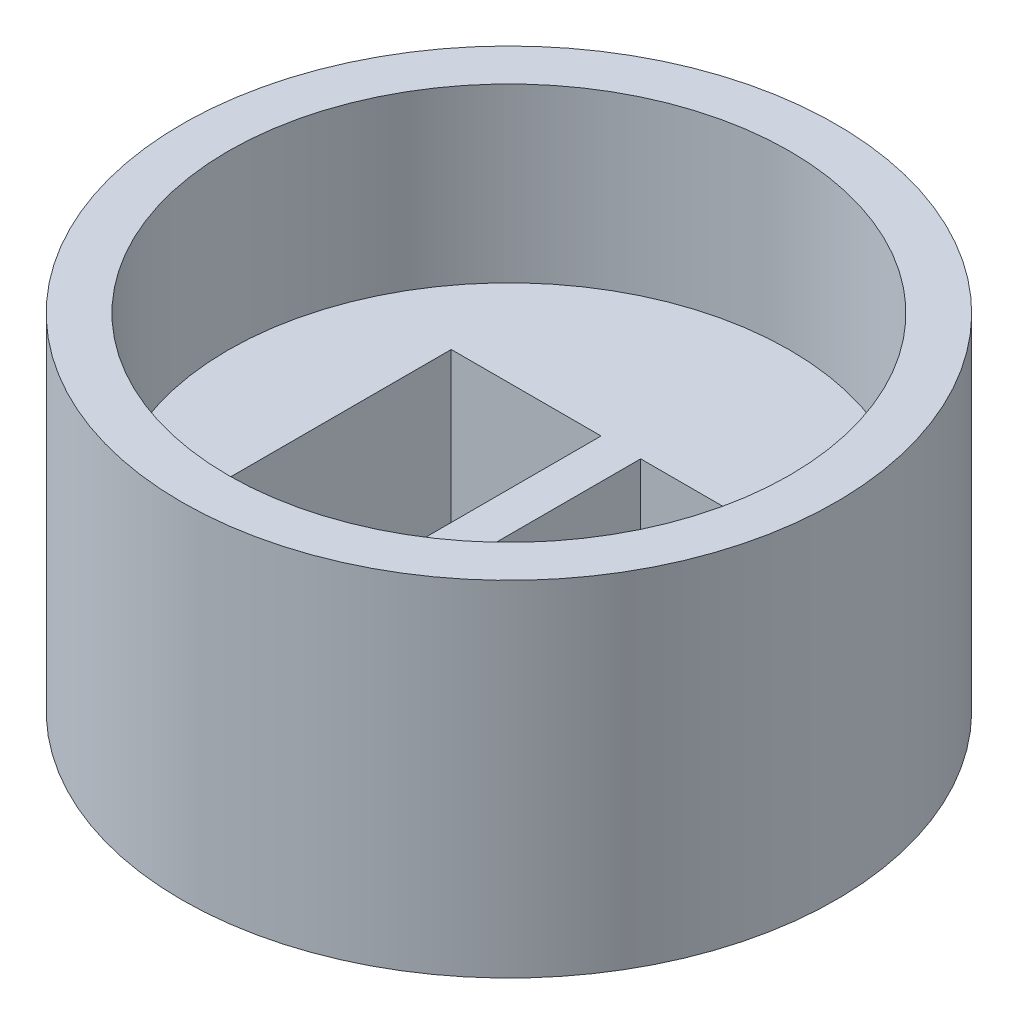
from build123d import *

# Parameters (mm, degrees)
SKETCH2_R           = 9.5
BOSS_EXTRUDE2_DEPTH = 10
SKETCH3_R           = 8.15
CUT_EXTRUDE1_DEPTH  = 5
SKETCH4_W           = 4.35
SKETCH4_H           = 6.5
CUT_EXTRUDE2_DEPTH  = 6


with BuildPart() as part:
    # Sketch2 → Boss-Extrude2 (new body)
    with BuildSketch(Plane(origin=(0, 0, 0), x_dir=(1, 0, 0), z_dir=(0, 1, 0))):
        Circle(SKETCH2_R)
    extrude(amount=BOSS_EXTRUDE2_DEPTH)

    # Sketch3 → Cut-Extrude1 (cut)
    with BuildSketch(Plane(origin=(0, 10, 0), x_dir=(1, 0, 0), z_dir=(0, 1, 0))):
        Circle(SKETCH3_R)
    extrude(amount=-CUT_EXTRUDE1_DEPTH, mode=Mode.SUBTRACT)

    # Sketch4 → Cut-Extrude2 (cut, through all)
    with BuildSketch(Plane(origin=(0, 5, 0), x_dir=(1, 0, 0), z_dir=(0, 1, 0))):
        with Locations((2.75, 0)):
            Rectangle(SKETCH4_W, SKETCH4_H)
        with Locations((-2.75, 0)):
            Rectangle(SKETCH4_W, SKETCH4_H)
    extrude(amount=-CUT_EXTRUDE2_DEPTH, mode=Mode.SUBTRACT)


solid = part.part
